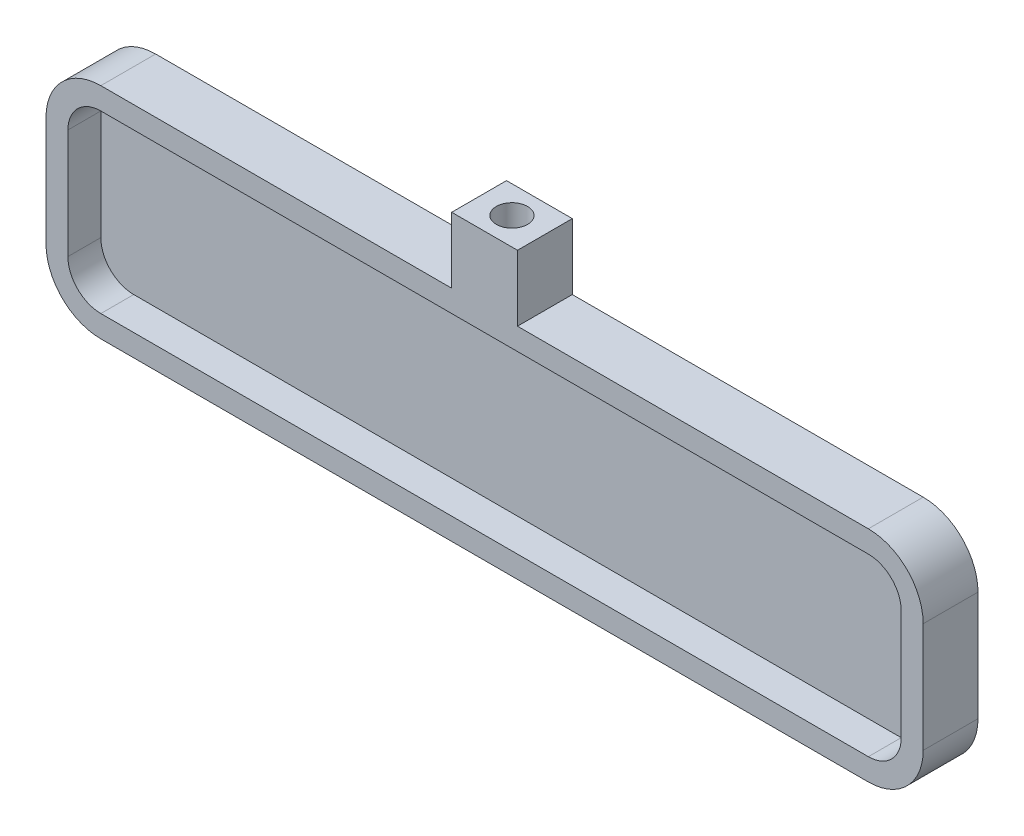
from build123d import *

# Parameters (mm, degrees)
SKETCH1_W           = 80
SKETCH1_H           = 20
BOSS_EXTRUDE1_DEPTH = 5
FILLET1_R           = 5
SHELL1_T            = -2
SKETCH2_W           = 6
SKETCH2_H           = 5
BOSS_EXTRUDE2_DEPTH = 6
SKETCH3_R           = 1.425
CUT_EXTRUDE1_DEPTH  = 4


with BuildPart() as part:
    # Sketch1 → Boss-Extrude1 (new body)
    with BuildSketch(Plane.XY):
        Rectangle(SKETCH1_W, SKETCH1_H)
    extrude(amount=BOSS_EXTRUDE1_DEPTH)

    # Fillet1
    fillet1_edges = [part.edges().sort_by_distance(p)[0] for p in [
        (40, -10, 2.5),
        (-40, -10, 2.5),
        (-40, 10, 2.5),
        (40, 10, 2.5),
    ]]
    fillet(fillet1_edges, radius=FILLET1_R)

    # Shell1
    shell1_openings = [part.faces().sort_by_distance(p)[0] for p in [
        (0, 0, 5),
    ]]
    offset(amount=SHELL1_T, openings=shell1_openings, kind=Kind.INTERSECTION)

    # Sketch2 → Boss-Extrude2 (add)
    with BuildSketch(Plane(origin=(0, 10, 0), x_dir=(1, 0, 0), z_dir=(0, 1, 0))):
        with Locations((0, -2.5)):
            Rectangle(SKETCH2_W, SKETCH2_H)
    extrude(amount=BOSS_EXTRUDE2_DEPTH)

    # Sketch3 → Cut-Extrude1 (cut)
    with BuildSketch(Plane(origin=(0, 16, 0), x_dir=(1, 0, 0), z_dir=(0, 1, 0))):
        with Locations((-0.00192903, -2.502672146)):
            Circle(SKETCH3_R)
    extrude(amount=-CUT_EXTRUDE1_DEPTH, mode=Mode.SUBTRACT)


solid = part.part
